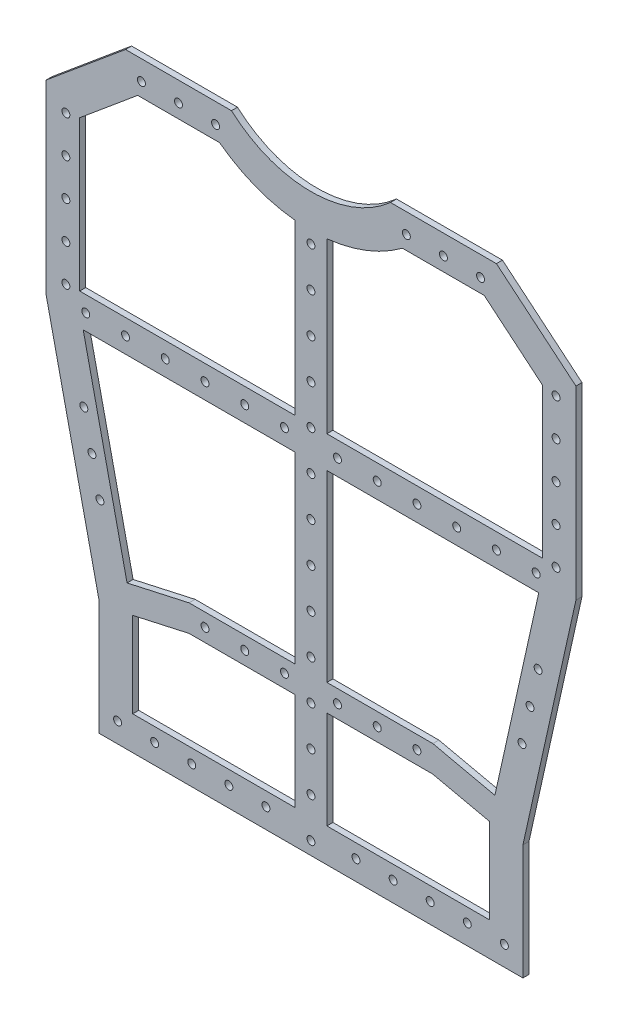
from build123d import *

# Parameters (mm, degrees)
BOSS_EXTRUDE1_DEPTH    = 2.286
SKETCH8_W              = 160
SKETCH8_H              = 1.5
CUT_EXTRUDE3_DEPTH     = 10
CUT_EXTRUDE4_DEPTH     = 3.286
BOSS_EXTRUDE2_DEPTH    = 2.286
F_3_0MM_DOWEL_HOLE4_D  = 3
F_3_0MM_DOWEL_HOLE5_D  = 3
F_3_0MM_DOWEL_HOLE6_D  = 3
F_3_0MM_DOWEL_HOLE7_D  = 3
F_3_0MM_DOWEL_HOLE8_D  = 3
F_3_0MM_DOWEL_HOLE9_D  = 3
F_3_0MM_DOWEL_HOLE10_D = 3


with BuildPart() as part:
    # Sketch1 → Boss-Extrude1 (new body)
    with BuildSketch(Plane.XY):
        with BuildLine():
            Line((-30, 6.458980338), (-70, 6.458980338))
            Line((-70, 6.458980338), (-100, -18.541019662))
            Line((-100, -18.541019662), (-100, -88.541019662))
            Line((-100, -88.541019662), (-80, -178.541019662))
            Line((-80, -178.541019662), (-80, -223.541019662))
            Line((-80, -223.541019662), (80, -223.541019662))
            Line((80, -223.541019662), (80, -178.541019662))
            Line((80, -178.541019662), (100, -88.541019662))
            Line((100, -88.541019662), (100, -18.541019662))
            Line((100, -18.541019662), (70, 6.458980338))
            Line((70, 6.458980338), (30, 6.458980338))
            ThreePointArc((30, 6.458980338), (0, -5), (-30, 6.458980338))
        make_face()
    extrude(amount=BOSS_EXTRUDE1_DEPTH)

    # Sketch8 → Cut-Extrude3 (cut)
    with BuildSketch(Plane.XY.offset(2.286)):
        with Locations((0, -222.791019662)):
            Rectangle(SKETCH8_W, SKETCH8_H)
    extrude(amount=-CUT_EXTRUDE3_DEPTH, mode=Mode.SUBTRACT)

    # Sketch15 → Cut-Extrude4 (cut, through all)
    with BuildSketch(Plane.XY.offset(2.286)):
        with BuildLine():
            Line((-87.3, -24.489381476), (-87.3, -81.146912359))
            Line((-87.3, -81.146912359), (-6, -81.146912359))
            Line((-6, -81.146912359), (-6, -17.387193693))
            ThreePointArc((-6, -17.387193693), (-21.008544759, -13.739473826), (-34.511709615, -6.241019662))
            Line((-34.511709615, -6.241019662), (-65.401965823, -6.241019662))
            Line((-65.401965823, -6.241019662), (-87.3, -24.489381476))
        make_face()
        with BuildLine():
            Line((6, -81.146912359), (87.3, -81.146912359))
            Line((87.3, -81.146912359), (87.3, -24.489381476))
            Line((87.3, -24.489381476), (65.401965823, -6.241019662))
            Line((65.401965823, -6.241019662), (34.511709615, -6.241019662))
            ThreePointArc((34.511709615, -6.241019662), (21.008544759, -13.739473826), (6, -17.387193693))
            Line((6, -17.387193693), (6, -81.146912359))
        make_face()
        Polygon((-67.3, -209.341019662), (-6, -209.341019662), (-6, -93.146912359), (-85.966666667, -93.146912359), (-67.3, -177.146912359), align=None)
        Polygon((6, -93.146912359), (6, -209.341019662), (67.3, -209.341019662), (67.3, -177.146912359), (85.966666667, -93.146912359), align=None)
    extrude(amount=-CUT_EXTRUDE4_DEPTH, mode=Mode.SUBTRACT)

    # Sketch16 → Boss-Extrude2 (add)
    with BuildSketch(Plane.XY.offset(2.286)):
        Polygon((-67.3, -177.146912359), (-46, -172.413579025), (-6, -172.413579025), (-6, -162.413579025), (-46, -162.413579025), (-69.417647059, -167.617500594), align=None)
    boss_extrude2 = extrude(amount=-BOSS_EXTRUDE2_DEPTH)

    # Mirror1: Boss-Extrude2 across plane
    add(boss_extrude2.mirror(Plane(origin=(0, 0, 0), x_dir=(0, 0, 1), z_dir=(1, 0, 0))))

    # Ø3.0mm Dowel Hole4 (through all)
    with Locations(Plane.XY.offset(2.286)):
        with Locations((-85, -87.146912359), (-70, -87.146912359), (-55, -87.146912359), (-40, -87.146912359), (-25, -87.146912359), (-10, -87.146912359), (10, -87.146912359), (25, -87.146912359), (40, -87.146912359), (55, -87.146912359), (70, -87.146912359), (85, -87.146912359)):
            Hole(F_3_0MM_DOWEL_HOLE4_D / 2)

    # Ø3.0mm Dowel Hole5 (through all)
    with Locations(Plane.XY.offset(2.286)):
        with Locations((0, -22.146912359), (0, -37.146912359), (0, -52.146912359), (0, -67.146912359), (0, -82.146912359), (0, -97.146912359), (0, -112.146912359), (0, -127.146912359), (0, -142.146912359), (0, -157.146912359), (0, -172.146912359), (0, -187.146912359), (0, -202.146912359), (0, -217.146912359)):
            Hole(F_3_0MM_DOWEL_HOLE5_D / 2)

    # Ø3.0mm Dowel Hole6 (through all)
    with Locations(Plane.XY.offset(2.286)):
        with Locations((-40, -167.413579025), (-25, -167.413579025), (-10, -167.413579025), (10, -167.413579025), (25, -167.413579025), (40, -167.413579025)):
            Hole(F_3_0MM_DOWEL_HOLE6_D / 2)

    # Ø3.0mm Dowel Hole7 (through all)
    with Locations(Plane(origin=(0, 0, 0), x_dir=(-1, 0, 0), z_dir=(0, 0, -1))):
        with Locations((92.507, -25.541019662), (92.507, -39.541019662), (92.507, -53.541019662), (92.507, -67.541019662), (92.507, -81.541019662)):
            f_3_0mm_dowel_hole7 = Hole(F_3_0MM_DOWEL_HOLE7_D / 2)

    # Mirror2: Ø3.0mm Dowel Hole7 across plane
    add(f_3_0mm_dowel_hole7.mirror(Plane(origin=(0, 0, 0), x_dir=(0, 0, 1), z_dir=(1, 0, 0))), mode=Mode.SUBTRACT)

    # Ø3.0mm Dowel Hole8 (through all)
    with Locations(Plane(origin=(0, 0, 0), x_dir=(-1, 0, 0), z_dir=(0, 0, -1))):
        with Locations((-73, -214.548019662), (-59, -214.548019662), (-45, -214.548019662), (-31, -214.548019662), (-17, -214.548019662), (17, -214.548019662), (31, -214.548019662), (45, -214.548019662), (59, -214.548019662), (73, -214.548019662)):
            Hole(F_3_0MM_DOWEL_HOLE8_D / 2)

    # Ø3.0mm Dowel Hole9 (through all)
    with Locations(Plane.XY.offset(2.286)):
        with Locations((-64, -1.034019662), (-50, -1.034019662), (-36, -1.034019662), (36, -1.034019662), (50, -1.034019662), (64, -1.034019662)):
            Hole(F_3_0MM_DOWEL_HOLE9_D / 2)

    # Ø3.0mm Dowel Hole10 (through all)
    with Locations(Plane.XY.offset(2.286)):
        with Locations((-85.721962662, -118.251164374), (-82.684936253, -131.917783217), (-79.647909843, -145.584402059)):
            f_3_0mm_dowel_hole10 = Hole(F_3_0MM_DOWEL_HOLE10_D / 2)

    # Mirror3: Ø3.0mm Dowel Hole10 across plane
    add(f_3_0mm_dowel_hole10.mirror(Plane(origin=(0, 0, 0), x_dir=(0, 0, 1), z_dir=(1, 0, 0))), mode=Mode.SUBTRACT)


solid = part.part
